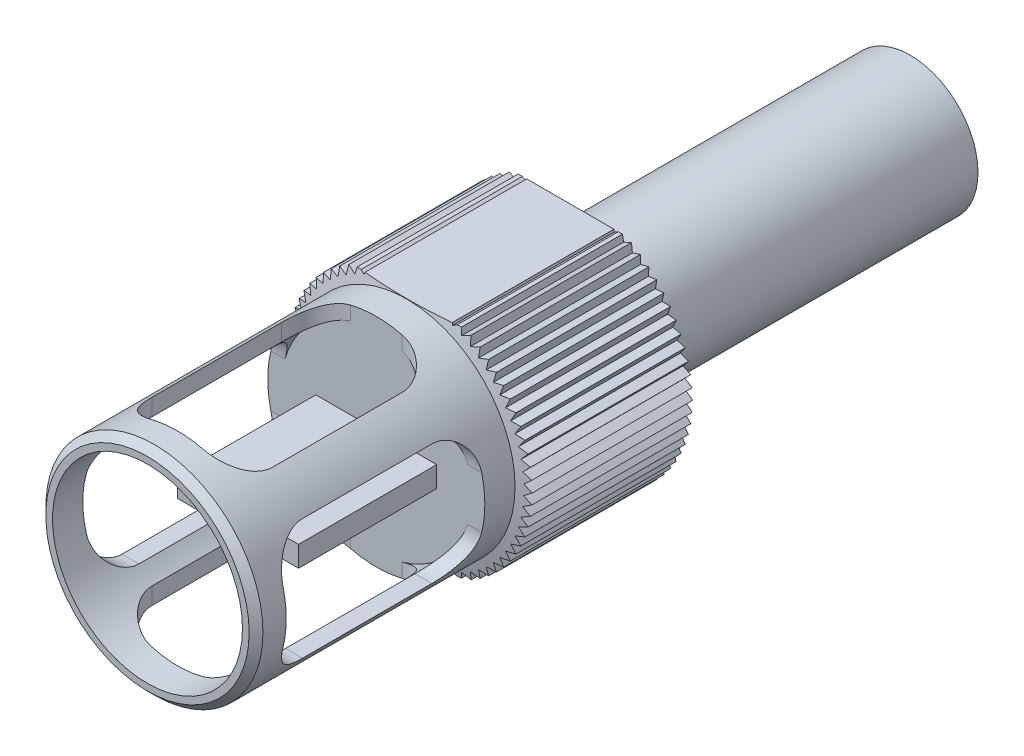
from build123d import *

# Parameters (mm, degrees)
CUT_EXTRUDE1_DEPTH  = 32.1
CIRPATTERN1_COUNT   = 72
CUT_EXTRUDE2_DEPTH  = 57.1
CUT_EXTRUDE3_DEPTH  = 10
CIRPATTERN3_COUNT   = 3
CIRPATTERN3_ANGLE   = 180
SKETCH6_R           = 6.985
CUT_EXTRUDE4_DEPTH  = 16.8275
SKETCH7_W           = 8.89
SKETCH7_H           = 1.524
BOSS_EXTRUDE1_DEPTH = 10.16


with BuildPart() as part:
    # Sketch2 → Revolve1 (revolve)
    with BuildSketch(Plane(origin=(0, 0, 0), x_dir=(0, 0, -1), z_dir=(1, 0, 0))):
        Polygon((0, 0), (0, 7.476), (0.508, 7.984), (19.05, 7.984), (19.304, 9), (31.1, 9), (31.1, 4.984), (56.1, 4.984), (56.1, 0), align=None)
    revolve(axis=Axis((0, 0, 0), (0, 0, -1)))

    # Sketch3 → Cut-Extrude1 (cut, through all)
    with BuildSketch(Plane(origin=(0, 0, -31.1), x_dir=(-1, 0, 0), z_dir=(0, 0, -1))):
        with BuildLine():
            ThreePointArc((0.784401685, 8.965752283), (0.392574486, 8.991433994), (0, 9))
            Line((0, 9), (0.370415838, 8.483917498))
            Line((0.370415838, 8.483917498), (0.784401685, 8.965752283))
        make_face()
    cut_extrude1 = extrude(amount=-CUT_EXTRUDE1_DEPTH, mode=Mode.SUBTRACT)

    # CirPattern1: Cut-Extrude1 ×72 about axis
    cirpattern1_axis = Axis((0, 0, 0), (0, 0, 1))
    for i in range(1, CIRPATTERN1_COUNT):
        add(cut_extrude1.rotate(cirpattern1_axis, i * 360 / CIRPATTERN1_COUNT), mode=Mode.SUBTRACT)

    # Sketch4 → Cut-Extrude2 (cut, through all)
    with BuildSketch(Plane.XY):
        with BuildLine():
            ThreePointArc((9.863569334, 8), (0, 12.7), (-9.863569334, 8))
            Line((-9.863569334, 8), (9.863569334, 8))
        make_face()
        with BuildLine():
            Line((9.863569334, -8), (-9.863569334, -8))
            ThreePointArc((-9.863569334, -8), (0, -12.7), (9.863569334, -8))
        make_face()
    extrude(amount=-CUT_EXTRUDE2_DEPTH, mode=Mode.SUBTRACT)

    # Sketch5 → Cut-Extrude3 (cut, symmetric)
    with BuildSketch(Plane(origin=(0, 0, 0), x_dir=(0, 0, -1), z_dir=(1, 0, 0))):
        with BuildLine():
            Line((14.2875, -4.445), (4.7625, -4.445))
            ThreePointArc((4.7625, -4.445), (2.966448776, -3.701051224), (2.2225, -1.905))
            Line((2.2225, -1.905), (2.2225, 1.905))
            ThreePointArc((2.2225, 1.905), (2.966448776, 3.701051224), (4.7625, 4.445))
            Line((4.7625, 4.445), (14.2875, 4.445))
            ThreePointArc((14.2875, 4.445), (16.083551224, 3.701051224), (16.8275, 1.905))
            Line((16.8275, 1.905), (16.8275, -1.905))
            ThreePointArc((16.8275, -1.905), (16.083551224, -3.701051224), (14.2875, -4.445))
        make_face()
    cut_extrude3 = extrude(amount=CUT_EXTRUDE3_DEPTH, both=True, mode=Mode.SUBTRACT)

    # CirPattern3: Cut-Extrude3 ×3 about axis
    cirpattern3_axis = Axis((0, 0, 0), (0, 0, 1))
    for i in range(1, CIRPATTERN3_COUNT):
        add(cut_extrude3.rotate(cirpattern3_axis, i * CIRPATTERN3_ANGLE / (CIRPATTERN3_COUNT - 1)), mode=Mode.SUBTRACT)

    # Sketch6 → Cut-Extrude4 (cut)
    with BuildSketch(Plane.XY):
        Circle(SKETCH6_R)
    extrude(amount=-CUT_EXTRUDE4_DEPTH, mode=Mode.SUBTRACT)

    # Sketch7 → Boss-Extrude1 (add)
    with BuildSketch(Plane.XY.offset(-16.8275)):
        Rectangle(SKETCH7_W, SKETCH7_H)
    extrude(amount=BOSS_EXTRUDE1_DEPTH)


solid = part.part
